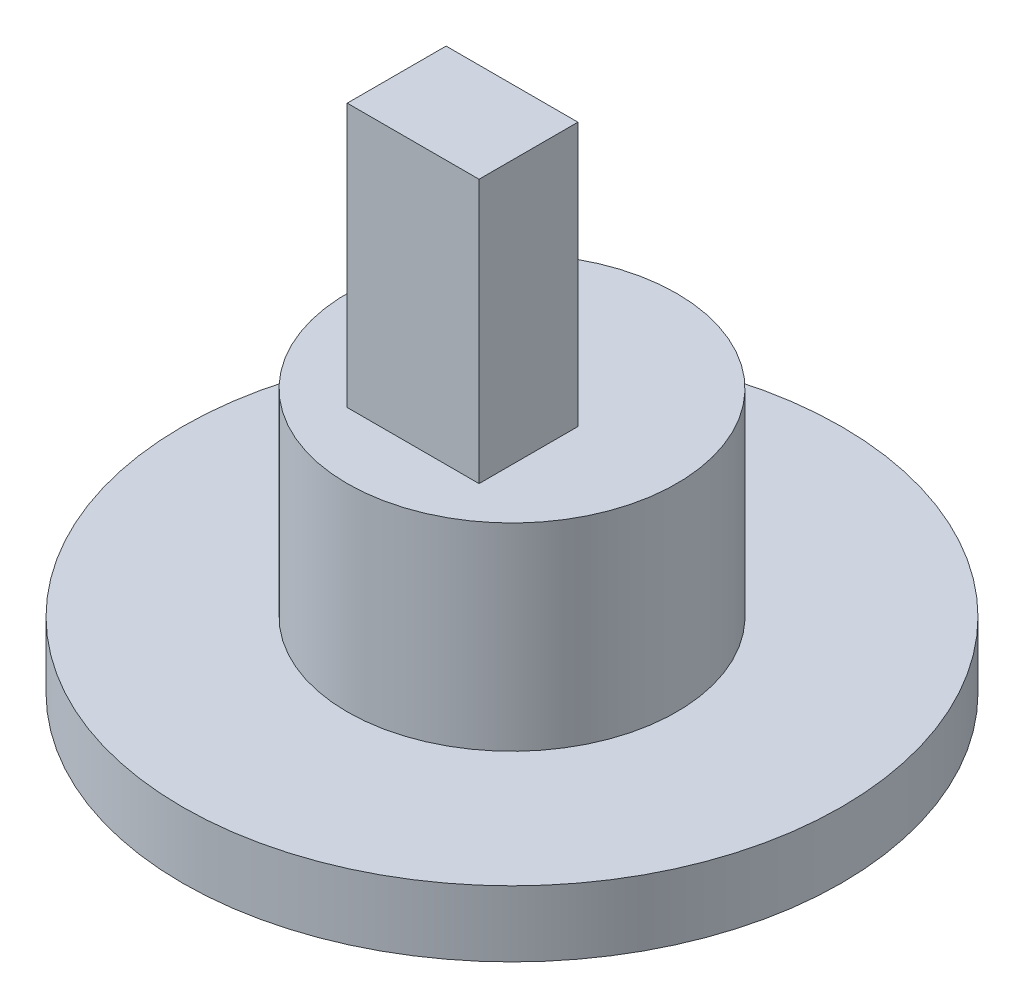
from build123d import *

# Parameters (mm, degrees)
SKETCH1_R           = 5
BOSS_EXTRUDE1_DEPTH = 6
SKETCH3_W           = 4
SKETCH3_H           = 3
BOSS_EXTRUDE2_DEPTH = 8
SKETCH4_R           = 10
BOSS_EXTRUDE3_DEPTH = 2


with BuildPart() as part:
    # Sketch1 → Boss-Extrude1 (new body)
    with BuildSketch(Plane(origin=(0, 0, 0), x_dir=(1, 0, 0), z_dir=(0, 1, 0))):
        Circle(SKETCH1_R)
    extrude(amount=BOSS_EXTRUDE1_DEPTH)

    # Sketch3 → Boss-Extrude2 (add)
    with BuildSketch(Plane(origin=(0, 6, 0), x_dir=(1, 0, 0), z_dir=(0, 1, 0))):
        with Locations((0, -1.5)):
            Rectangle(SKETCH3_W, SKETCH3_H)
    extrude(amount=BOSS_EXTRUDE2_DEPTH)

    # Sketch4 → Boss-Extrude3 (add)
    with BuildSketch(Plane.XZ):
        Circle(SKETCH4_R)
    extrude(amount=BOSS_EXTRUDE3_DEPTH)


solid = part.part
